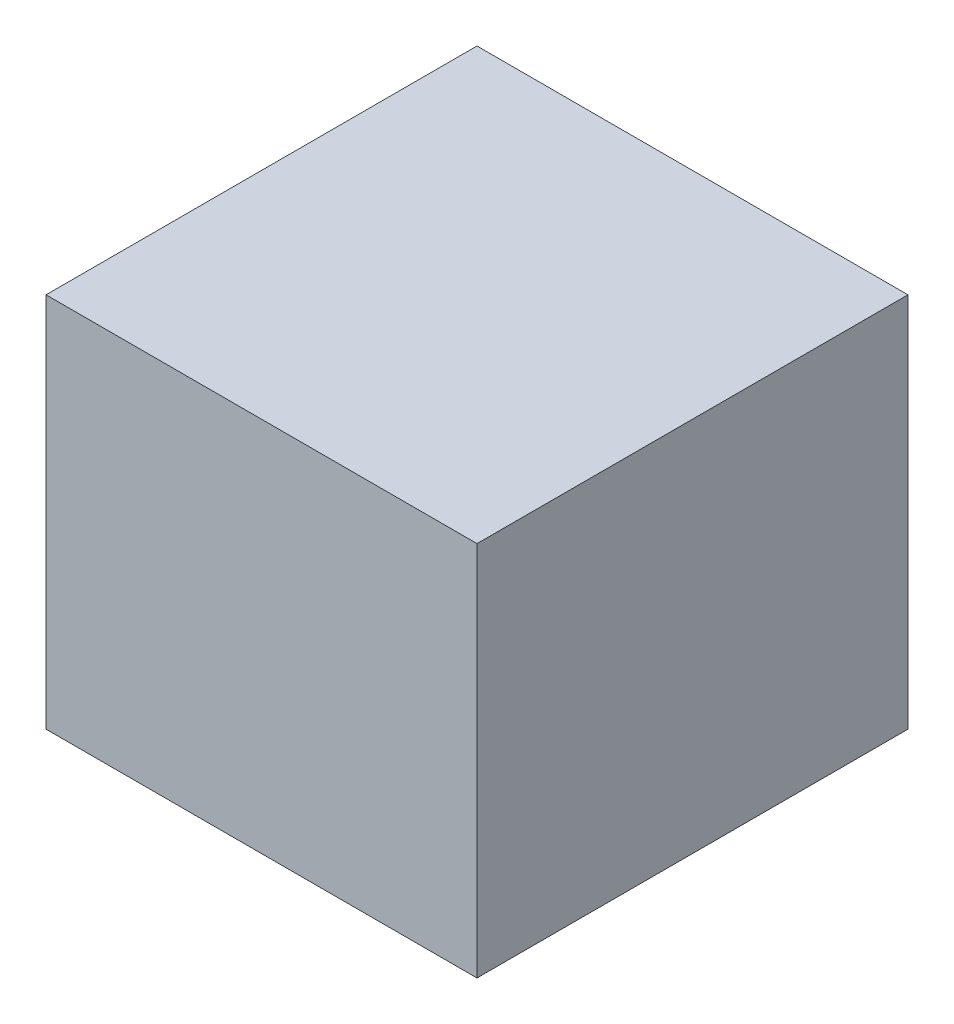
from build123d import *

# Parameters (mm, degrees)
SKETCH1_W           = 183.896
SKETCH1_H           = 183.896
BOSS_EXTRUDE1_DEPTH = 160.528


with BuildPart() as part:
    # Sketch1 → Boss-Extrude1 (new body)
    with BuildSketch(Plane(origin=(0, 0, 0), x_dir=(1, 0, 0), z_dir=(0, 1, 0))):
        Rectangle(SKETCH1_W, SKETCH1_H)
    extrude(amount=BOSS_EXTRUDE1_DEPTH)


solid = part.part
